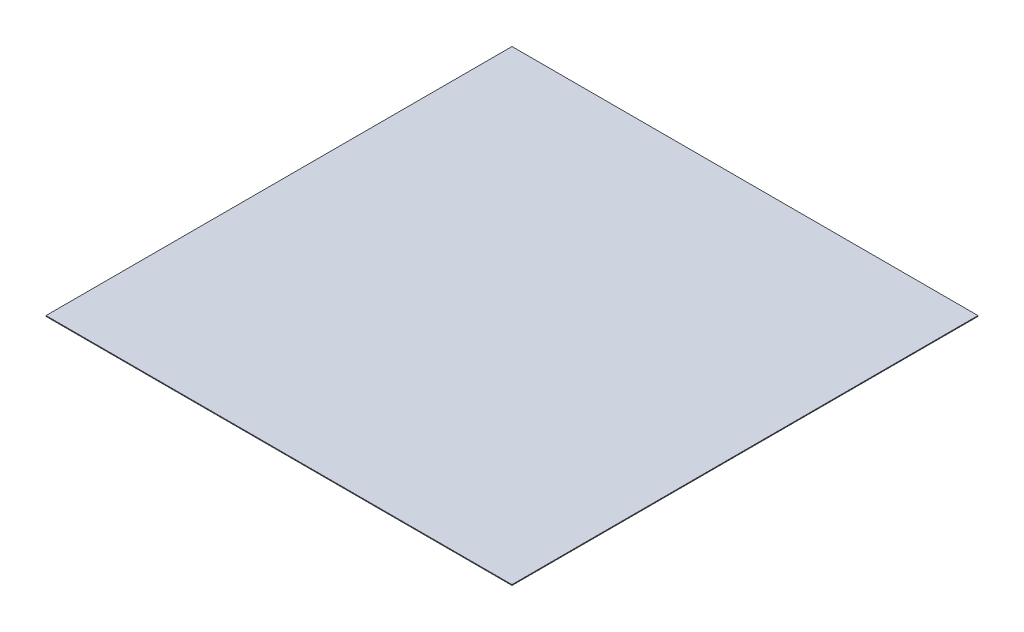
from build123d import *

# Parameters (mm, degrees)
SKETCH3_W           = 30000
SKETCH3_H           = 30000
BOSS_EXTRUDE2_DEPTH = 50
SKETCH8_R           = 25.4
BOSS_EXTRUDE4_DEPTH = 100
BOSS_EXTRUDE5_DEPTH = 300
SKETCH10_W          = 80
SKETCH10_H          = 80
BOSS_EXTRUDE6_DEPTH = 100


with BuildPart() as part:
    # Sketch3 → Boss-Extrude2 (new body)
    with BuildSketch(Plane(origin=(0, 0, 0), x_dir=(1, 0, 0), z_dir=(0, 1, 0))):
        Rectangle(SKETCH3_W, SKETCH3_H)
    extrude(amount=BOSS_EXTRUDE2_DEPTH)

    # Sketch8 → Boss-Extrude4 (add)
    with BuildSketch(Plane.XZ):
        with Locations((0, 215.9)):
            Circle(SKETCH8_R)
        with Locations((186.974884677, 107.95)):
            Circle(SKETCH8_R)
        with Locations((186.974884677, -107.95)):
            Circle(SKETCH8_R)
        with Locations((0, -215.9)):
            Circle(SKETCH8_R)
        with Locations((-186.974884677, -107.95)):
            Circle(SKETCH8_R)
        with Locations((-186.974884677, 107.95)):
            Circle(SKETCH8_R)
    extrude(amount=BOSS_EXTRUDE4_DEPTH)

    # Sketch9 → Boss-Extrude5 (add)
    with BuildSketch(Plane.XZ):
        Polygon((400, 200), (800, -200), (400, -200), align=None)
        Polygon((400, 200), (800, 200), (800, -200), align=None)
        Polygon((200, 400), (-200, 400), (-200, 800), align=None)
        Polygon((200, 400), (-200, 800), (200, 800), align=None)
    extrude(amount=BOSS_EXTRUDE5_DEPTH)


with BuildPart() as body_2:
    # Sketch10 → Boss-Extrude6 (new body)
    with BuildSketch(Plane.XZ.offset(300)):
        with Locations((600, 0)):
            Rectangle(SKETCH10_W, SKETCH10_H)
    extrude(amount=BOSS_EXTRUDE6_DEPTH)


solid = Compound([part.part, body_2.part])
